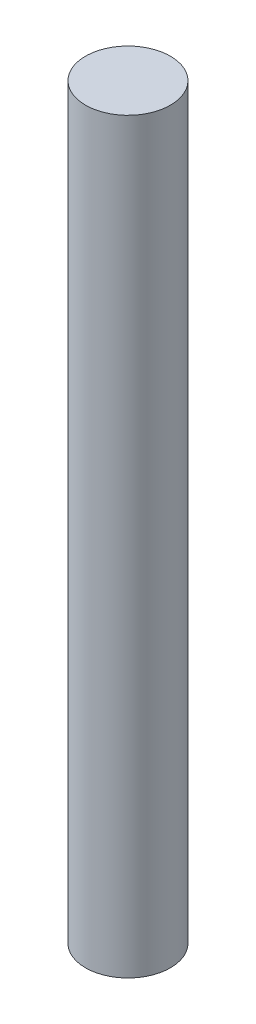
from build123d import *

# Parameters (mm, degrees)
SKETCH1_R           = 15.875
BOSS_EXTRUDE1_DEPTH = 279.4


with BuildPart() as part:
    # Sketch1 → Boss-Extrude1 (new body)
    with BuildSketch(Plane(origin=(0, 0, 0), x_dir=(1, 0, 0), z_dir=(0, 1, 0))):
        Circle(SKETCH1_R)
    extrude(amount=BOSS_EXTRUDE1_DEPTH)


solid = part.part
